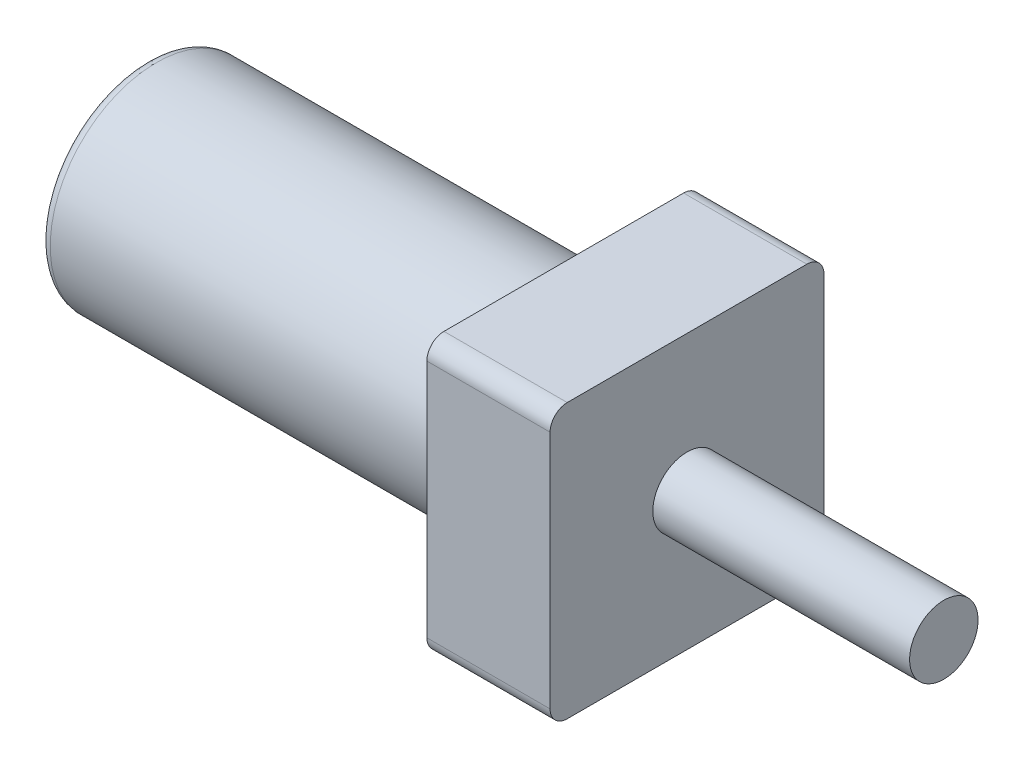
from build123d import *

# Parameters (mm, degrees)
SKETCH2_W           = 101.6
SKETCH2_H           = 101.6
BOSS_EXTRUDE1_DEPTH = 45.72
FILLET1_R           = 6.35
FILLET2_R           = 3.81


with BuildPart() as part:
    # Sketch1 → Revolve1 (revolve)
    with BuildSketch(Plane.XY):
        Polygon((154.94, 12.7), (295.91, 12.7), (295.91, 0), (0, 0), (0, 39.37), (154.94, 39.37), align=None)
    revolve(axis=Axis((-49.711428571, 0, 0), (1, 0, 0)))

    # Sketch2 → Boss-Extrude1 (add)
    with BuildSketch(Plane(origin=(154.94, 0, 0), x_dir=(0, 0, -1), z_dir=(1, 0, 0))):
        Rectangle(SKETCH2_W, SKETCH2_H)
    extrude(amount=BOSS_EXTRUDE1_DEPTH)

    # Fillet1
    fillet1_edges = [part.edges().sort_by_distance(p)[0] for p in [
        (177.8, 50.8, 50.8),
        (177.8, -50.8, 50.8),
        (177.8, -50.8, -50.8),
        (177.8, 50.8, -50.8),
    ]]
    fillet(fillet1_edges, radius=FILLET1_R)

    # Fillet2
    fillet2_edges = [part.edges().sort_by_distance(p)[0] for p in [
        (0, -39.37, 0),
    ]]
    fillet(fillet2_edges, radius=FILLET2_R)


solid = part.part
